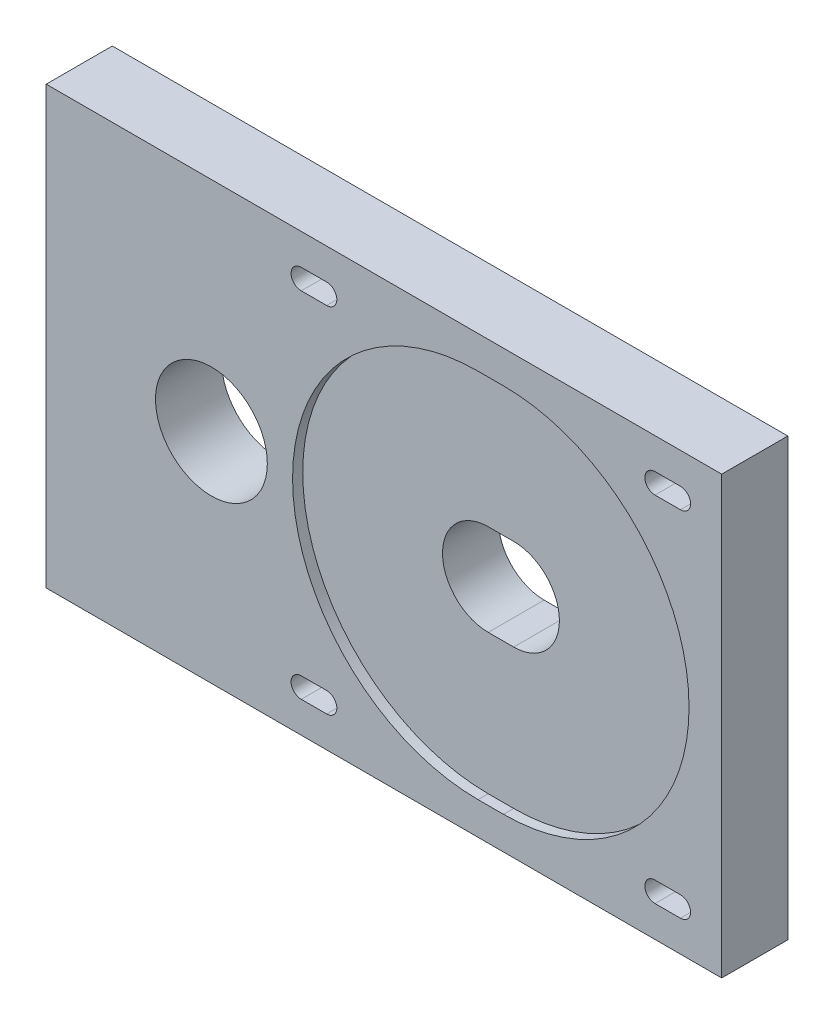
from build123d import *

# Parameters (mm, degrees)
SZKIC1_W                    = 132.9
SZKIC1_H                    = 85.85
DODANIE_WYCI_GNI_CIE1_DEPTH = 13
SZKIC2_R                    = 36.5
SZKIC2_W                    = 5
SZKIC2_H                    = 73
WYTNIJ_WYCI_GNI_CIE1_DEPTH  = 2
WYTNIJ_WYCI_GNI_CIE3_DEPTH  = 13
SZYK_LINIOWY1_COUNT         = 2
SZYK_LINIOWY1_PITCH         = 69.6
SZYK_LINIOWY1_COUNT_DIR2    = 2
SZYK_LINIOWY1_PITCH_DIR2    = 69.6
WYTNIJ_WYCI_GNI_CIE4_DEPTH  = 13
SZKIC7_R                    = 11
WYTNIJ_WYCI_GNI_CIE5_DEPTH  = 13
SZKIC8_R                    = 3
WYTNIJ_WYCI_GNI_CIE6_DEPTH  = 25


with BuildPart() as part:
    # Szkic1 → Dodanie-wyciągnięcie1 (new body)
    with BuildSketch(Plane.XY):
        Rectangle(SZKIC1_W, SZKIC1_H)
    extrude(amount=DODANIE_WYCI_GNI_CIE1_DEPTH)

    # Szkic2 → Wytnij-wyciągnięcie1 (cut)
    with BuildSketch(Plane.XY.offset(13)):
        with Locations((23.52, 0)):
            Circle(SZKIC2_R)
        with Locations((18.52, 0)):
            Circle(SZKIC2_R)
        with Locations((21.02, 0)):
            Rectangle(SZKIC2_W, SZKIC2_H)
    extrude(amount=-WYTNIJ_WYCI_GNI_CIE1_DEPTH, mode=Mode.SUBTRACT)

    # Szkic3 → Wytnij-wyciągnięcie3 (cut)
    with BuildSketch(Plane.XY.offset(13)):
        with BuildLine():
            ThreePointArc((55.325, 34.8), (54.739213562, 36.214213562), (53.325, 36.8))
            Line((53.325, 36.8), (53.325, 32.8))
            ThreePointArc((53.325, 32.8), (54.739213562, 33.385786438), (55.325, 34.8))
        make_face()
        with BuildLine():
            Line((53.325, 32.8), (53.325, 36.8))
            ThreePointArc((53.325, 36.8), (51.325, 34.8), (53.325, 32.8))
        make_face()
        with BuildLine():
            Line((58.325, 36.8), (53.325, 36.8))
            ThreePointArc((53.325, 36.8), (54.739213562, 36.214213562), (55.325, 34.8))
            ThreePointArc((55.325, 34.8), (54.739213562, 33.385786438), (53.325, 32.8))
            Line((53.325, 32.8), (58.325, 32.8))
            ThreePointArc((58.325, 32.8), (56.325, 34.8), (58.325, 36.8))
        make_face()
        with BuildLine():
            ThreePointArc((60.325, 34.8), (59.739213562, 36.214213562), (58.325, 36.8))
            Line((58.325, 36.8), (58.325, 32.8))
            ThreePointArc((58.325, 32.8), (59.739213562, 33.385786438), (60.325, 34.8))
        make_face()
        with BuildLine():
            Line((58.325, 32.8), (58.325, 36.8))
            ThreePointArc((58.325, 36.8), (56.325, 34.8), (58.325, 32.8))
        make_face()
    wytnij_wyci_gni_cie3 = extrude(amount=-WYTNIJ_WYCI_GNI_CIE3_DEPTH, mode=Mode.SUBTRACT)

    # Szyk liniowy1: Wytnij-wyci_gni_cie3 2 × 2
    with Locations(*[(-j * SZYK_LINIOWY1_PITCH_DIR2, -i * SZYK_LINIOWY1_PITCH, 0) for i in range(SZYK_LINIOWY1_COUNT) for j in range(SZYK_LINIOWY1_COUNT_DIR2) if (i, j) != (0, 0)]):
        add(wytnij_wyci_gni_cie3, mode=Mode.SUBTRACT)

    # Szkic6 → Wytnij-wyciągnięcie4 (cut)
    with BuildSketch(Plane.XY.offset(13)):
        with BuildLine():
            ThreePointArc((21.02, 8.645808233), (19.782482852, 8.911012123), (18.52, 9))
            Line((18.52, 9), (18.52, 7.483314774))
            ThreePointArc((18.52, 7.483314774), (19.725220987, 8.160860999), (21.02, 8.645808233))
        make_face()
        with BuildLine():
            Line((18.52, 7.483314774), (18.52, 9))
            ThreePointArc((18.52, 9), (9.52, 0), (18.52, -9))
            Line((18.52, -9), (18.52, -7.483314774))
            ThreePointArc((18.52, -7.483314774), (14.52, 0), (18.52, 7.483314774))
        make_face()
        with BuildLine():
            Line((18.52, -7.483314774), (18.52, -9))
            ThreePointArc((18.52, -9), (19.782482852, -8.911012123), (21.02, -8.645808233))
            ThreePointArc((21.02, -8.645808233), (19.725220987, -8.160860999), (18.52, -7.483314774))
        make_face()
        with BuildLine():
            Line((18.52, -7.483314774), (18.52, 7.483314774))
            ThreePointArc((18.52, 7.483314774), (14.52, 0), (18.52, -7.483314774))
        make_face()
        with BuildLine():
            ThreePointArc((21.02, 8.645808233), (19.725220987, 8.160860999), (18.52, 7.483314774))
            Line((18.52, 7.483314774), (18.52, -7.483314774))
            ThreePointArc((18.52, -7.483314774), (19.725220987, -8.160860999), (21.02, -8.645808233))
            ThreePointArc((21.02, -8.645808233), (22.314779013, -8.160860999), (23.52, -7.483314774))
            Line((23.52, -7.483314774), (23.52, 7.483314774))
            ThreePointArc((23.52, 7.483314774), (22.314779013, 8.160860999), (21.02, 8.645808233))
        make_face()
        with BuildLine():
            ThreePointArc((27.52, 0), (26.457253933, 4.242640687), (23.52, 7.483314774))
            Line((23.52, 7.483314774), (23.52, -7.483314774))
            ThreePointArc((23.52, -7.483314774), (26.457253933, -4.242640687), (27.52, 0))
        make_face()
        with BuildLine():
            ThreePointArc((32.52, 0), (29.883961031, 6.363961031), (23.52, 9))
            Line((23.52, 9), (23.52, 7.483314774))
            ThreePointArc((23.52, 7.483314774), (26.457253933, 4.242640687), (27.52, 0))
            ThreePointArc((27.52, 0), (26.457253933, -4.242640687), (23.52, -7.483314774))
            Line((23.52, -7.483314774), (23.52, -9))
            ThreePointArc((23.52, -9), (29.883961031, -6.363961031), (32.52, 0))
        make_face()
        with BuildLine():
            Line((23.52, 7.483314774), (23.52, 9))
            ThreePointArc((23.52, 9), (22.257517148, 8.911012123), (21.02, 8.645808233))
            ThreePointArc((21.02, 8.645808233), (22.314779013, 8.160860999), (23.52, 7.483314774))
        make_face()
        with BuildLine():
            ThreePointArc((21.02, -8.645808233), (22.257517148, -8.911012123), (23.52, -9))
            Line((23.52, -9), (23.52, -7.483314774))
            ThreePointArc((23.52, -7.483314774), (22.314779013, -8.160860999), (21.02, -8.645808233))
        make_face()
        with BuildLine():
            ThreePointArc((21.02, -8.645808233), (19.782482852, -8.911012123), (18.52, -9))
            Line((18.52, -9), (23.52, -9))
            ThreePointArc((23.52, -9), (22.257517148, -8.911012123), (21.02, -8.645808233))
        make_face()
        with BuildLine():
            Line((23.52, 9), (18.52, 9))
            ThreePointArc((18.52, 9), (19.782482852, 8.911012123), (21.02, 8.645808233))
            ThreePointArc((21.02, 8.645808233), (22.257517148, 8.911012123), (23.52, 9))
        make_face()
    extrude(amount=-WYTNIJ_WYCI_GNI_CIE4_DEPTH, mode=Mode.SUBTRACT)

    # Szkic7 → Wytnij-wyciągnięcie5 (cut)
    with BuildSketch(Plane.XY.offset(13)):
        with Locations((-33.95, 0)):
            Circle(SZKIC7_R)
    extrude(amount=-WYTNIJ_WYCI_GNI_CIE5_DEPTH, mode=Mode.SUBTRACT)

    # Szkic8 → Wytnij-wyciągnięcie6 (cut)
    with BuildSketch(Plane.ZY.offset(66.45)):
        with Locations((6.5, 34.925)):
            Circle(SZKIC8_R)
        with Locations((6.5, -34.925)):
            Circle(SZKIC8_R)
    extrude(amount=-WYTNIJ_WYCI_GNI_CIE6_DEPTH, mode=Mode.SUBTRACT)


solid = part.part
